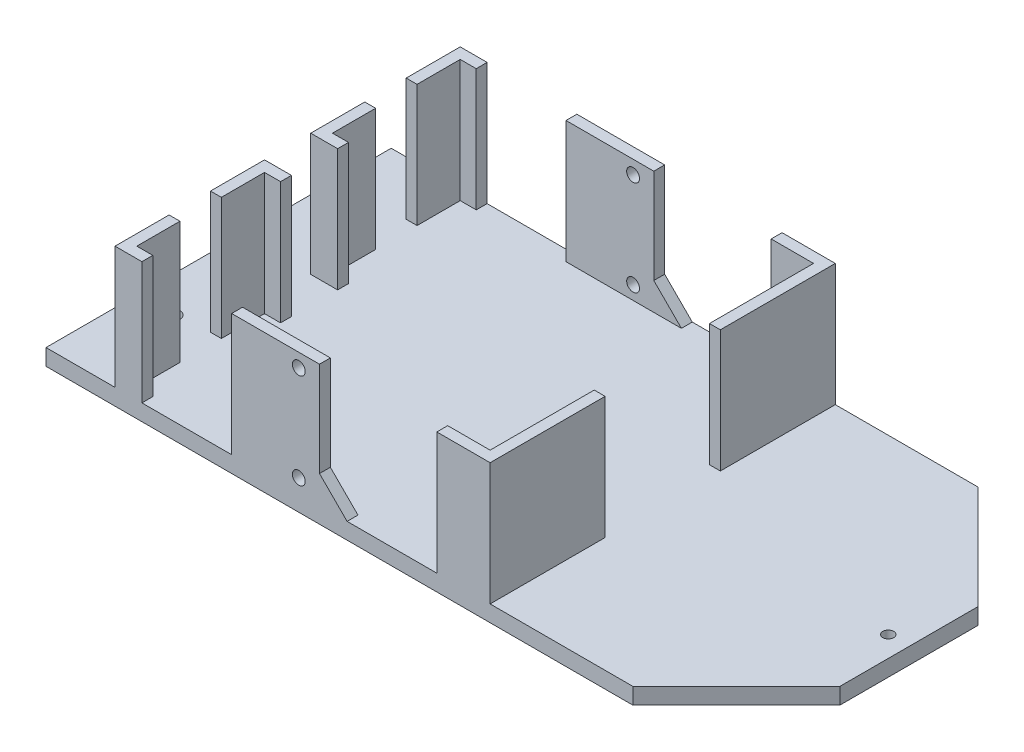
from build123d import *

# Parameters (mm, degrees)
SKETCH1_W               = 127
SKETCH1_H               = 63.5
BOSS_EXTRUDE1_DEPTH     = 3
BOSS_EXTRUDE2_DEPTH     = 22.5
SKETCH3_W               = 15.24
SKETCH3_H               = 22.5
CUT_EXTRUDE1_DEPTH      = 132.466012718
SKETCH4_W               = 2
SKETCH4_H               = 7.94
SKETCH4_H_2             = 19.15
BOSS_EXTRUDE4_DEPTH     = 22.5
SKETCH5_W               = 16.51
SKETCH5_H               = 22.5
CUT_EXTRUDE2_DEPTH      = 93.004075997
CUT_EXTRUDE2_DEPTH_BACK = 93.004075997
SKETCH6_W               = 12.7
SKETCH6_H               = 2
CUT_EXTRUDE3_DEPTH      = 22.5
CUT_EXTRUDE4_DEPTH      = 94.352825346
CUT_EXTRUDE5_DEPTH      = 76.43581709
F_2_0MM_DOWEL_HOLE1_D   = 2
SKETCH13_W              = 34.845
SKETCH13_H              = 22.5
CUT_EXTRUDE6_DEPTH      = 12.5
F_3_0MM_DOWEL_HOLE1_D   = 3
CUT_EXTRUDE7_DEPTH      = 94.352825346


with BuildPart() as part:
    # Sketch1 → Boss-Extrude1 (new body)
    with BuildSketch(Plane(origin=(0, 0, 0), x_dir=(1, 0, 0), z_dir=(0, 1, 0))):
        Rectangle(SKETCH1_W, SKETCH1_H)
    extrude(amount=BOSS_EXTRUDE1_DEPTH)

    # Sketch2 → Boss-Extrude2 (add)
    with BuildSketch(Plane(origin=(0, 3, 0), x_dir=(1, 0, 0), z_dir=(0, 1, 0))):
        Polygon((-63.5, 29.75), (-61.5, 29.75), (61.5, 29.75), (61.5, -29.75), (-61.5, -29.75), (-63.5, -29.75), (-63.5, -31.75), (63.5, -31.75), (63.5, 31.75), (-63.5, 31.75), align=None)
    extrude(amount=BOSS_EXTRUDE2_DEPTH)

    # Sketch3 → Cut-Extrude1 (cut, through all)
    with BuildSketch(Plane.ZY.offset(-61.5)):
        with Locations((0, 14.25)):
            Rectangle(SKETCH3_W, SKETCH3_H)
    extrude(amount=-CUT_EXTRUDE1_DEPTH, mode=Mode.SUBTRACT)

    # Sketch4 → Boss-Extrude4 (add)
    with BuildSketch(Plane(origin=(0, 3, 0), x_dir=(1, 0, 0), z_dir=(0, 1, 0))):
        with Locations((-49.8, -25.78)):
            Rectangle(SKETCH4_W, SKETCH4_H)
        with Locations((17.2, -20.175)):
            Rectangle(SKETCH4_W, SKETCH4_H_2)
        Polygon((-50.8, -14.19), (-48.8, -14.19), (-48.8, -6.25), (5.5, -6.25), (5.5, -4.25), (-50.8, -4.25), align=None)
        with Locations((-49.8, 25.78)):
            Rectangle(SKETCH4_W, SKETCH4_H)
        Polygon((-48.8, 14.19), (-50.8, 14.19), (-50.8, 4.25), (5.5, 4.25), (5.5, 6.25), (-48.8, 6.25), align=None)
        with Locations((17.2, 20.175)):
            Rectangle(SKETCH4_W, SKETCH4_H_2)
    extrude(amount=BOSS_EXTRUDE4_DEPTH)

    # Sketch5 → Cut-Extrude2 (cut, two sides)
    with BuildSketch(Plane(origin=(0, 0, 29.75), x_dir=(-1, 0, 0), z_dir=(0, 0, -1))) as cut_extrude2_sk:
        with Locations((37.6, 14.25)):
            Rectangle(SKETCH5_W, SKETCH5_H)
    extrude(amount=CUT_EXTRUDE2_DEPTH, mode=Mode.SUBTRACT)
    extrude(cut_extrude2_sk.sketch, amount=-CUT_EXTRUDE2_DEPTH_BACK, mode=Mode.SUBTRACT)

    # Sketch6 → Cut-Extrude3 (cut)
    with BuildSketch(Plane(origin=(0, 25.5, 0), x_dir=(1, 0, 0), z_dir=(0, 1, 0))):
        Polygon((18.2, 29.75), (18.2, 31.75), (63.5, 31.75), (63.5, 7.62), (61.5, 7.62), (61.5, 29.75), align=None)
        Polygon((18.2, -29.75), (18.2, -31.75), (63.5, -31.75), (63.5, -7.62), (61.5, -7.62), (61.5, -29.75), align=None)
        with Locations((-57.15, 30.75)):
            Rectangle(SKETCH6_W, SKETCH6_H)
        with Locations((-57.15, -30.75)):
            Rectangle(SKETCH6_W, SKETCH6_H)
    extrude(amount=-CUT_EXTRUDE3_DEPTH, mode=Mode.SUBTRACT)

    # Sketch8 → Cut-Extrude4 (cut, through all)
    with BuildSketch(Plane.XY.offset(31.75)):
        with BuildLine():
            ThreePointArc((-17, 24.1811), (-18.1811, 23), (-17, 21.8189))
            Line((-17, 21.8189), (-17, 24.1811))
        make_face()
        with BuildLine():
            Line((-17, 24.1811), (-17, 21.8189))
            ThreePointArc((-17, 21.8189), (-16.164836181, 22.164836181), (-15.8189, 23))
            ThreePointArc((-15.8189, 23), (-16.164836181, 23.835163819), (-17, 24.1811))
        make_face()
        with BuildLine():
            ThreePointArc((-17, 6.6811), (-18.1811, 5.5), (-17, 4.3189))
            Line((-17, 4.3189), (-17, 6.6811))
        make_face()
        with BuildLine():
            Line((-17, 6.6811), (-17, 4.3189))
            ThreePointArc((-17, 4.3189), (-16.164836181, 4.664836181), (-15.8189, 5.5))
            ThreePointArc((-15.8189, 5.5), (-16.164836181, 6.335163819), (-17, 6.6811))
        make_face()
    extrude(amount=-CUT_EXTRUDE4_DEPTH, mode=Mode.SUBTRACT)

    # Sketch10 → Cut-Extrude5 (cut, through all)
    with BuildSketch(Plane.XZ):
        Polygon((63.5, 31.75), (44.45, 31.75), (63.5, 12.7), align=None)
        Polygon((63.5, -31.75), (63.5, -12.7), (44.45, -31.75), align=None)
    extrude(amount=-CUT_EXTRUDE5_DEPTH, mode=Mode.SUBTRACT)

    # Ø2.0mm Dowel Hole1 (through all)
    with Locations(Plane(origin=(59.69, 0, 0), x_dir=(0, 0, -1), z_dir=(0, -1, 0))):
        with Locations((0, 0)):
            Hole(F_2_0MM_DOWEL_HOLE1_D / 2)

    # Sketch13 → Cut-Extrude6 (cut)
    with BuildSketch(Plane.XY.offset(6.25)):
        with Locations((-11.9225, 14.25)):
            Rectangle(SKETCH13_W, SKETCH13_H)
    extrude(amount=-CUT_EXTRUDE6_DEPTH, mode=Mode.SUBTRACT)

    # Ø3.0mm Dowel Hole1 (through all)
    with Locations(Plane(origin=(-57.15, 3, -15), x_dir=(0, 0, 1), z_dir=(0, 1, 0))):
        with Locations((0, 0), (30, 0)):
            Hole(F_3_0MM_DOWEL_HOLE1_D / 2)

    # Sketch16 → Cut-Extrude7 (cut, through all)
    with BuildSketch(Plane.XY.offset(31.75)):
        Polygon((8.4, 25.5), (-13.19, 25.5), (-13.19, 8.08), (-8.11, 3), (8.4, 3), align=None)
    extrude(amount=-CUT_EXTRUDE7_DEPTH, mode=Mode.SUBTRACT)


solid = part.part
